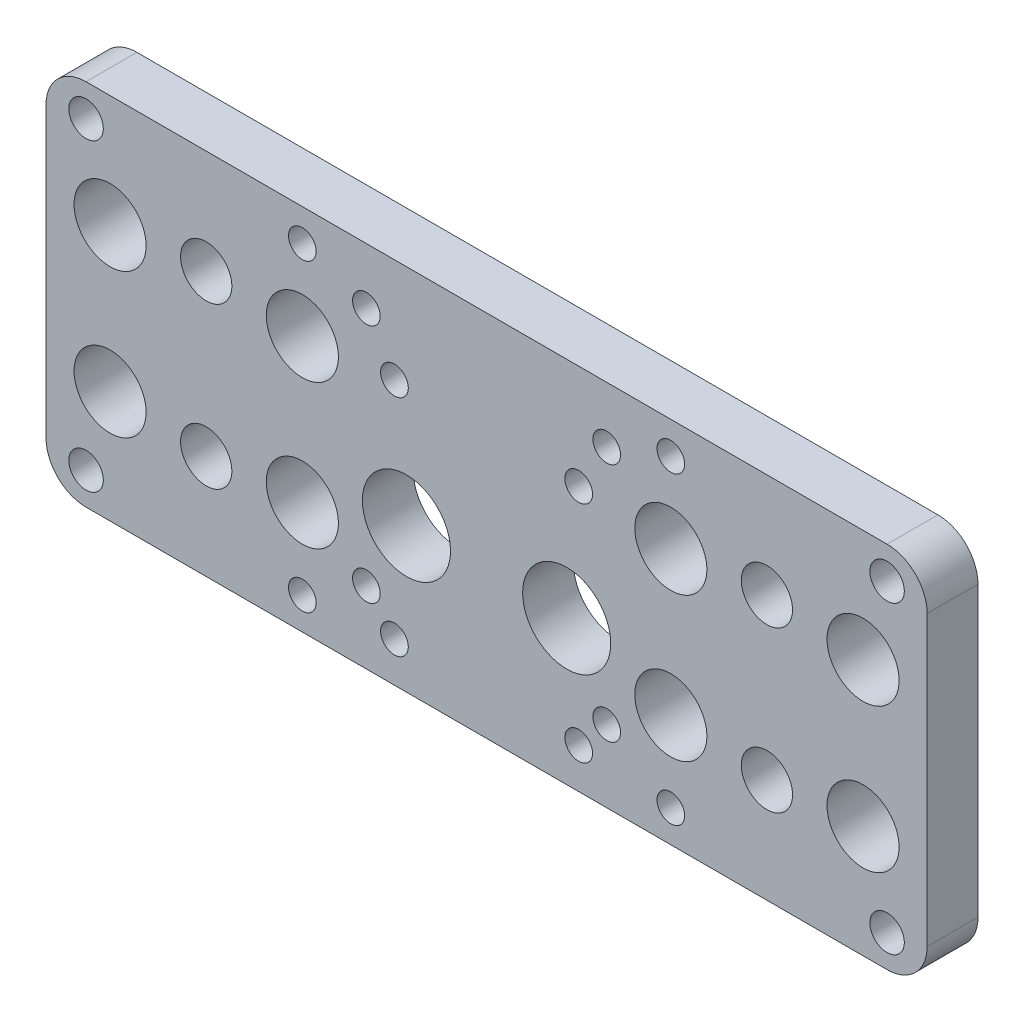
from build123d import *

# Parameters (mm, degrees)
SKETCH1_W             = 110
SKETCH1_H             = 46
BOSS_EXTRUDE1_DEPTH   = 6.35
M6_CLEARANCE_HOLE1_D  = 6.4
SKETCH5_R             = 5.5
CUT_EXTRUDE1_DEPTH    = 7.35
SKETCH7_R             = 4.5
CUT_EXTRUDE2_DEPTH    = 7.35
FILLET1_R             = 5
F_8_32_TAPPED_HOLE1_D = 3.4544
F_8_CLEARANCE_HOLE1_D = 4.3053
F_8_32_TAPPED_HOLE2_D = 3.4544


with BuildPart() as part:
    # Sketch1 → Boss-Extrude1 (new body)
    with BuildSketch(Plane.XY):
        Rectangle(SKETCH1_W, SKETCH1_H)
    extrude(amount=BOSS_EXTRUDE1_DEPTH)

    # M6 Clearance Hole1 (through all)
    with Locations(Plane(origin=(0, 0, 0), x_dir=(-1, 0, 0), z_dir=(0, 0, -1))):
        with Locations((-35, 10), (-35, -10), (35, -10), (35, 10)):
            Hole(M6_CLEARANCE_HOLE1_D / 2)

    # Sketch5 → Cut-Extrude1 (cut, through all)
    with BuildSketch(Plane(origin=(0, 0, 0), x_dir=(-1, 0, 0), z_dir=(0, 0, -1))):
        with Locations((-10, -5)):
            Circle(SKETCH5_R)
        with Locations((10, -5)):
            Circle(SKETCH5_R)
    extrude(amount=-CUT_EXTRUDE1_DEPTH, mode=Mode.SUBTRACT)

    # Sketch7 → Cut-Extrude2 (cut, through all)
    with BuildSketch(Plane(origin=(0, 0, 0), x_dir=(-1, 0, 0), z_dir=(0, 0, -1))):
        with Locations((-23, 9)):
            Circle(SKETCH7_R)
        with Locations((-23, -9)):
            Circle(SKETCH7_R)
        with Locations((23, -9)):
            Circle(SKETCH7_R)
        with Locations((23, 9)):
            Circle(SKETCH7_R)
        with Locations((-47, 9)):
            Circle(SKETCH7_R)
        with Locations((-47, -9)):
            Circle(SKETCH7_R)
        with Locations((47, 9)):
            Circle(SKETCH7_R)
        with Locations((47, -9)):
            Circle(SKETCH7_R)
    extrude(amount=-CUT_EXTRUDE2_DEPTH, mode=Mode.SUBTRACT)

    # Fillet1
    fillet1_edges = [part.edges().sort_by_distance(p)[0] for p in [
        (-55, -23, 3.175),
        (-55, 23, 3.175),
        (55, 23, 3.175),
        (55, -23, 3.175),
    ]]
    fillet(fillet1_edges, radius=FILLET1_R)

    # #8-32 Tapped Hole1 (through all)
    with Locations(Plane(origin=(0, 0, 0), x_dir=(-1, 0, 0), z_dir=(0, 0, -1))):
        with Locations((-23, 19), (23, 19), (23, -19), (-23, -19)):
            Hole(F_8_32_TAPPED_HOLE1_D / 2)

    # #8 Clearance Hole1 (through all)
    with Locations(Plane(origin=(0, 0, 0), x_dir=(-1, 0, 0), z_dir=(0, 0, -1))):
        with Locations((-50, 19), (-50, -19), (50, -19), (50, 19)):
            Hole(F_8_CLEARANCE_HOLE1_D / 2)

    # #8-32 Tapped Hole2 (through all)
    with Locations(Plane(origin=(0, 0, 0), x_dir=(-1, 0, 0), z_dir=(0, 0, -1))):
        with Locations((-11.5, 10), (11.5, 10), (11.5, -18), (-11.5, -18), (-15, -14), (15, -14), (15, 16), (-15, 16)):
            Hole(F_8_32_TAPPED_HOLE2_D / 2)


solid = part.part
